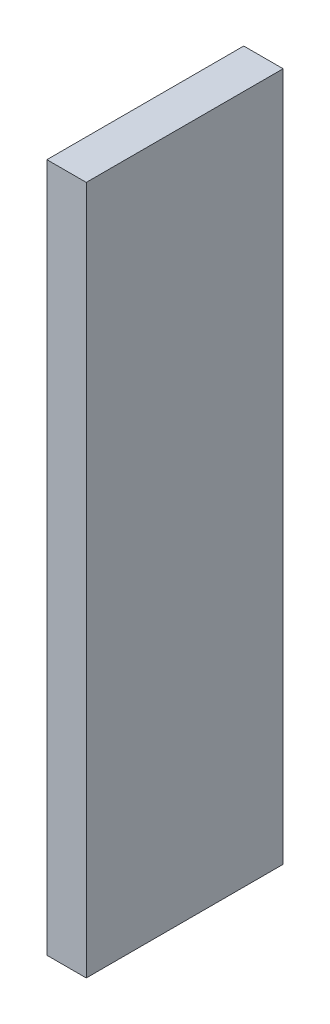
from build123d import *

# Parameters (mm, degrees)
SCHIZZO1_W                   = 4
SCHIZZO1_H                   = 70
ESTRUSIONE_ESTRUSIONE1_DEPTH = 20


with BuildPart() as part:
    # Schizzo1 → Estrusione-Estrusione1 (new body)
    with BuildSketch(Plane.XY):
        with Locations((-2, 0)):
            Rectangle(SCHIZZO1_W, SCHIZZO1_H)
    extrude(amount=ESTRUSIONE_ESTRUSIONE1_DEPTH)


solid = part.part
